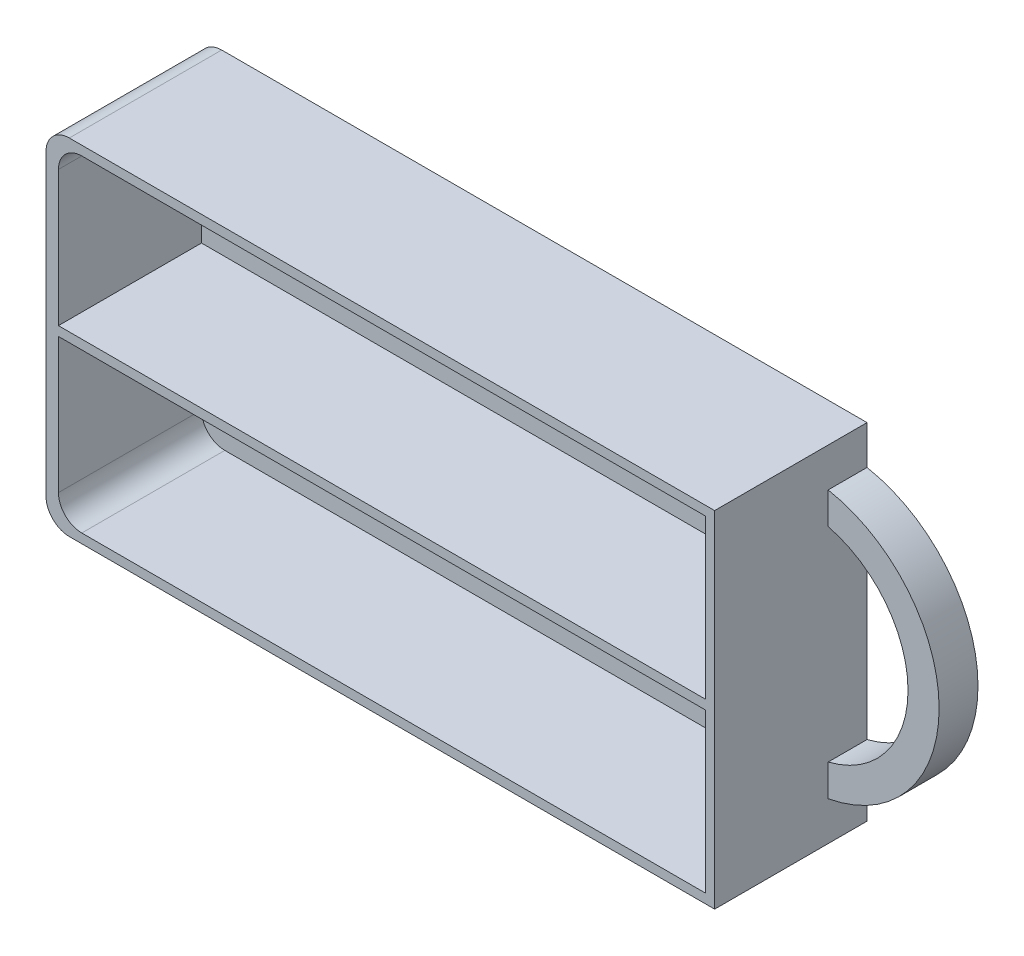
from build123d import *

# Parameters (mm, degrees)
SKETCH_1_W          = 86
SKETCH_1_H          = 44.4
EXTRUDE_1_DEPTH     = 19.6
EXTRUDE_2_DEPTH     = 5
SKETCH_3_W          = 83.2
SKETCH_3_H          = 20.402884615
SKETCH_3_H_2        = 20.397115385
CUT_EXTRUDE_1_DEPTH = 18.4
FILLET_1_R          = 3


with BuildPart() as part:
    # Эскиз1 → Бобышка-Вытянуть1 (new body)
    with BuildSketch(Plane.XY):
        Rectangle(SKETCH_1_W, SKETCH_1_H)
    extrude(amount=EXTRUDE_1_DEPTH)

    # Эскиз2 → Бобышка-Вытянуть2 (add)
    with BuildSketch(Plane.XY):
        with BuildLine():
            Line((43, 17.2), (43, 13.108775687))
            ThreePointArc((43, 13.108775687), (53.273546839, 0), (43, -13.108775687))
            Line((43, -13.108775687), (43, -17.2))
            ThreePointArc((43, -17.2), (57.273546839, 0), (43, 17.2))
        make_face()
    extrude(amount=EXTRUDE_2_DEPTH)

    # Эскиз3 → Вырез-Вытянуть1 (cut)
    with BuildSketch(Plane.XY.offset(19.6)):
        with Locations((0.2, 10.798557692)):
            Rectangle(SKETCH_3_W, SKETCH_3_H)
        with Locations((0.2, -10.801442308)):
            Rectangle(SKETCH_3_W, SKETCH_3_H_2)
    extrude(amount=-CUT_EXTRUDE_1_DEPTH, mode=Mode.SUBTRACT)

    # Скругление1
    fillet_1_edges = [part.edges().sort_by_distance(p)[0] for p in [
        (-41.4, 21, 10.4),
        (-41.4, -21, 10.4),
        (-43, -22.2, 9.8),
        (-43, 22.2, 9.8),
    ]]
    fillet(fillet_1_edges, radius=FILLET_1_R)


solid = part.part
